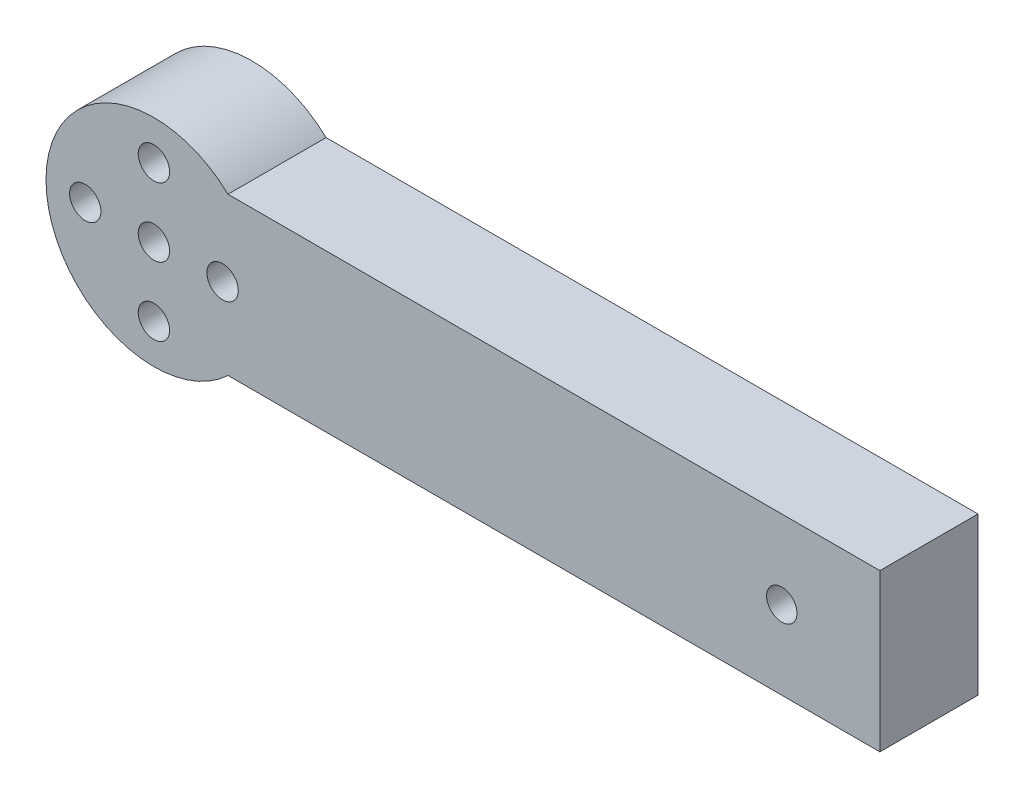
from build123d import *

# Parameters (mm, degrees)
SKETCH1_R           = 1.6
SKETCH1_R_2         = 1.55
BOSS_EXTRUDE1_DEPTH = 10


with BuildPart() as part:
    # Sketch1 → Boss-Extrude1 (new body)
    with BuildSketch(Plane.XY):
        with BuildLine():
            Line((82, 8), (82, -8))
            Line((82, -8), (15.549834435, -8))
            ThreePointArc((15.549834435, -8), (-3, 0), (15.549834435, 8))
            Line((15.549834435, 8), (82, 8))
        make_face()
        with Locations((8, 7)):
            Circle(SKETCH1_R, mode=Mode.SUBTRACT)
        with Locations((1, 0)):
            Circle(SKETCH1_R, mode=Mode.SUBTRACT)
        with Locations((8, -7)):
            Circle(SKETCH1_R, mode=Mode.SUBTRACT)
        with Locations((15, 0)):
            Circle(SKETCH1_R, mode=Mode.SUBTRACT)
        with Locations((8, 0)):
            Circle(SKETCH1_R, mode=Mode.SUBTRACT)
        with Locations((72, 0)):
            Circle(SKETCH1_R_2, mode=Mode.SUBTRACT)
    extrude(amount=BOSS_EXTRUDE1_DEPTH)


solid = part.part
